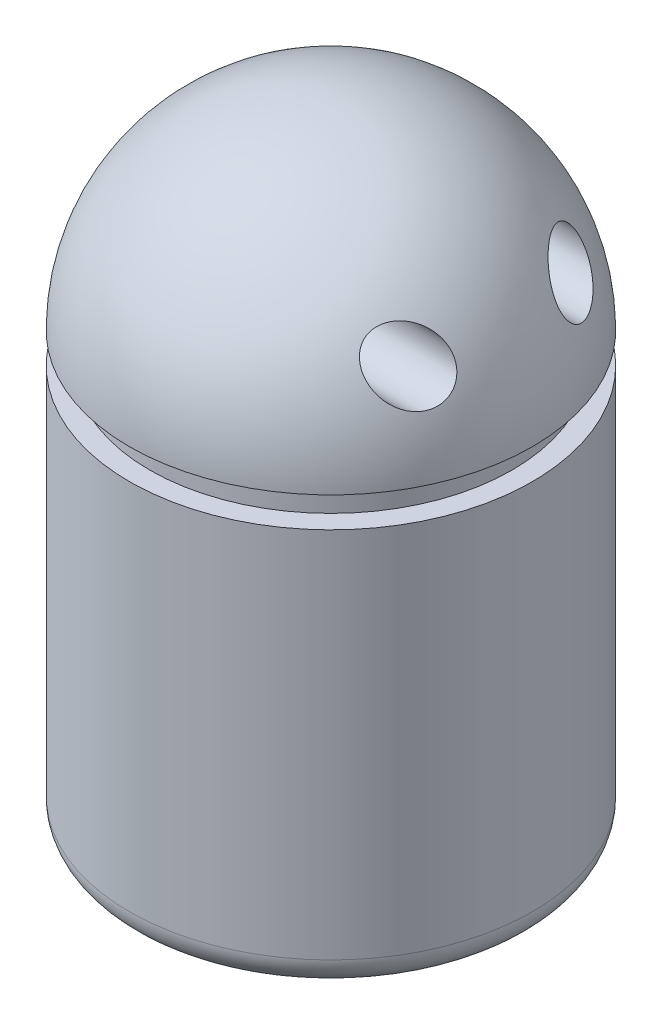
from build123d import *

# Parameters (mm, degrees)
REDONDEO3_R           = 3
CROQUIS9_R            = 3
CORTAR_EXTRUIR3_DEPTH = 18


with BuildPart() as part:
    # Croquis4 → Revolución4 (revolve)
    with BuildSketch(Plane.XY):
        with BuildLine():
            Line((20, -17.912835745), (20, 22.083900585))
            Line((20, 22.083900585), (18, 22.083900585))
            Line((18, 22.083900585), (18, 25.087164255))
            Line((18, 25.087164255), (20, 25.087164255))
            ThreePointArc((20, 25.087164255), (14.142135624, 39.229299878), (0, 45.087164255))
            Line((0, 45.087164255), (0, -17.912835745))
            Line((0, -17.912835745), (20, -17.912835745))
        make_face()
    revolve(axis=Axis((0, 45.087164255, 0), (0, -1, 0)))

    # Redondeo3
    redondeo3_edges = [part.edges().sort_by_distance(p)[0] for p in [
        (-20, -17.912835745, 0),
    ]]
    fillet(redondeo3_edges, radius=REDONDEO3_R)

    # Croquis9 → Cortar-Extruir3 (cut)
    with BuildSketch(Plane(origin=(0, 0, 0), x_dir=(0, 0, -1), z_dir=(1, 0, 0))):
        with Locations((8, 33.885616094)):
            Circle(CROQUIS9_R)
        with Locations((-8, 33.885616094)):
            Circle(CROQUIS9_R)
    extrude(amount=CORTAR_EXTRUIR3_DEPTH, mode=Mode.SUBTRACT)


solid = part.part
